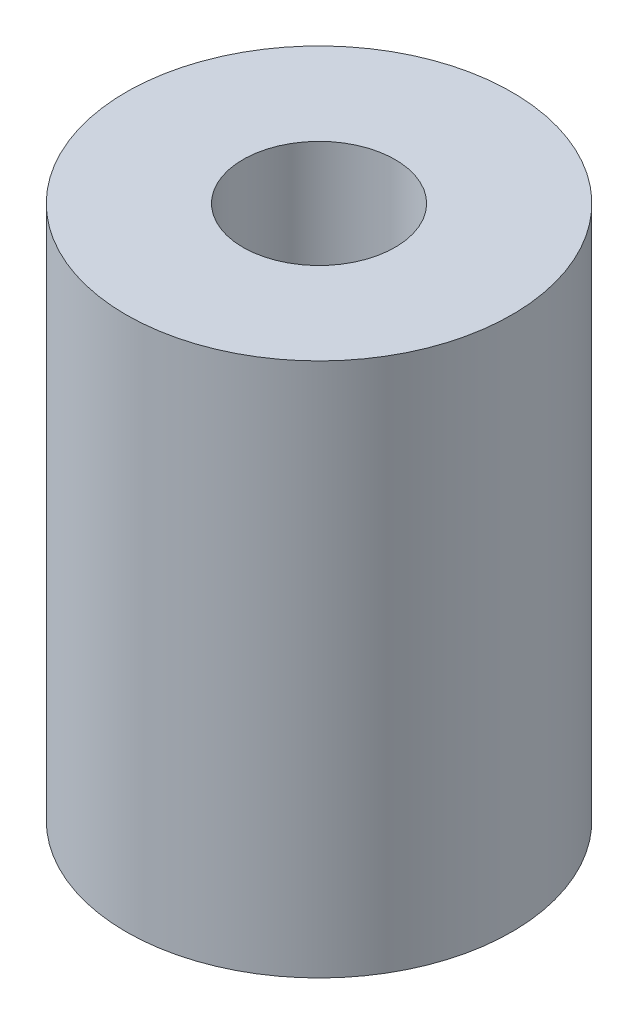
from build123d import *

# Parameters (mm, degrees)
SKETCH1_R           = 8.05
BOSS_EXTRUDE1_DEPTH = 11.15
SKETCH2_R           = 3.175
F_25_HOLE_DEPTH     = 7.4
SKETCH3_R           = 2.54
F_0_2_HOLE_DEPTH    = 7.4


with BuildPart() as part:
    # Sketch1 → Boss-Extrude1 (new body, symmetric)
    with BuildSketch(Plane(origin=(0, 0, 0), x_dir=(1, 0, 0), z_dir=(0, 1, 0))):
        Circle(SKETCH1_R)
    extrude(amount=BOSS_EXTRUDE1_DEPTH, both=True)

    # Sketch2 → .25" hole (cut)
    with BuildSketch(Plane(origin=(0, 11.15, 0), x_dir=(1, 0, 0), z_dir=(0, 1, 0))):
        Circle(SKETCH2_R)
    extrude(amount=-F_25_HOLE_DEPTH, mode=Mode.SUBTRACT)

    # Sketch3 → 0.2" hole (cut)
    with BuildSketch(Plane.XZ.offset(11.15)):
        Circle(SKETCH3_R)
    extrude(amount=-F_0_2_HOLE_DEPTH, mode=Mode.SUBTRACT)


solid = part.part
